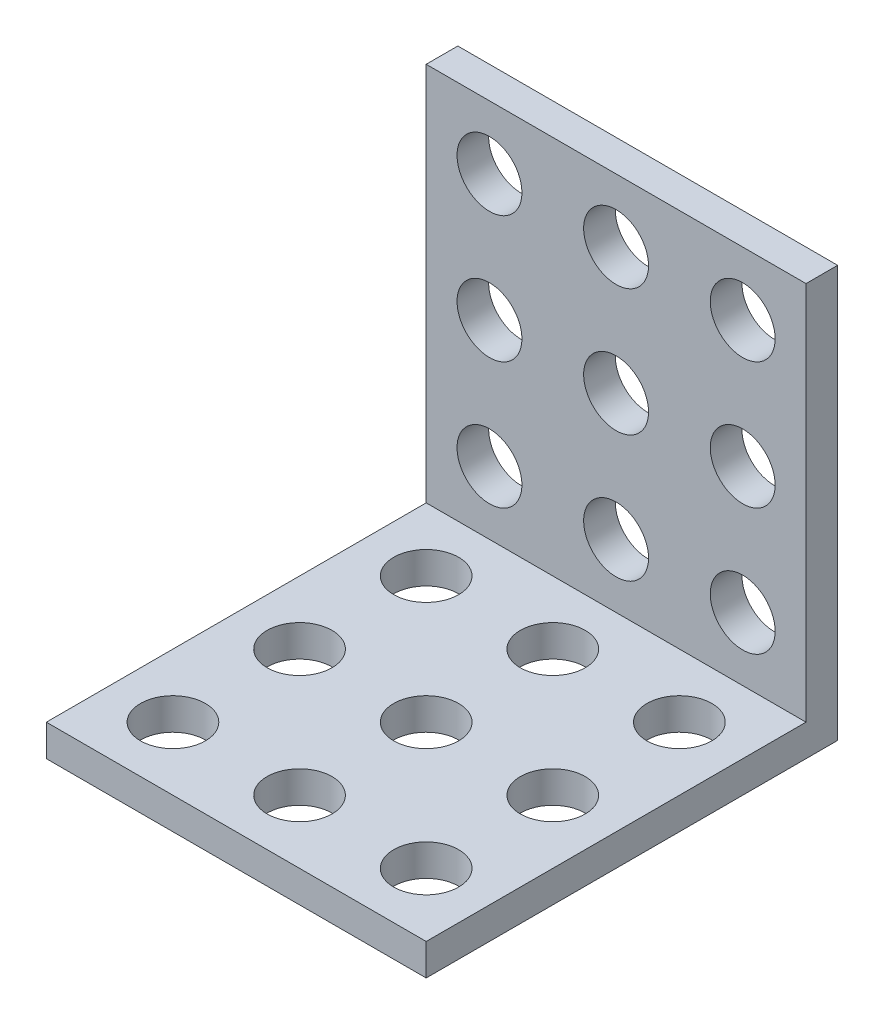
from build123d import *

# Parameters (mm, degrees)
BOSS_EXTRUDE1_DEPTH     = 12
SKETCH3_R               = 2.05
CUT_EXTRUDE1_DEPTH      = 25
CUT_EXTRUDE1_DEPTH_BACK = 3
SKETCH4_R               = 2.05
CUT_EXTRUDE2_DEPTH      = 3


with BuildPart() as part:
    # Sketch1 → Boss-Extrude1 (new body, symmetric)
    with BuildSketch(Plane(origin=(0, 0, 0), x_dir=(0, 0, -1), z_dir=(1, 0, 0))):
        Polygon((0, 0), (0, 26), (-2, 26), (-2, 2), (-26, 2), (-26, 0), align=None)
    extrude(amount=BOSS_EXTRUDE1_DEPTH, both=True)

    # Sketch3 → Cut-Extrude1 (cut, two sides)
    with BuildSketch(Plane.XY.offset(2)) as cut_extrude1_sk:
        with Locations((-8, 22)):
            Circle(SKETCH3_R)
        with Locations((0, 22)):
            Circle(SKETCH3_R)
        with Locations((8, 22)):
            Circle(SKETCH3_R)
        with Locations((0, 14)):
            Circle(SKETCH3_R)
        with Locations((8, 14)):
            Circle(SKETCH3_R)
        with Locations((0, 6)):
            Circle(SKETCH3_R)
        with Locations((8, 6)):
            Circle(SKETCH3_R)
        with Locations((-8, 14)):
            Circle(SKETCH3_R)
        with Locations((-8, 6)):
            Circle(SKETCH3_R)
    extrude(amount=CUT_EXTRUDE1_DEPTH, mode=Mode.SUBTRACT)
    extrude(cut_extrude1_sk.sketch, amount=-CUT_EXTRUDE1_DEPTH_BACK, mode=Mode.SUBTRACT)

    # Sketch4 → Cut-Extrude2 (cut, through all)
    with BuildSketch(Plane(origin=(0, 2, 0), x_dir=(1, 0, 0), z_dir=(0, 1, 0))):
        with Locations((-8, -22)):
            Circle(SKETCH4_R)
        with Locations((0, -22)):
            Circle(SKETCH4_R)
        with Locations((8, -22)):
            Circle(SKETCH4_R)
        with Locations((0, -14)):
            Circle(SKETCH4_R)
        with Locations((8, -14)):
            Circle(SKETCH4_R)
        with Locations((0, -6)):
            Circle(SKETCH4_R)
        with Locations((8, -6)):
            Circle(SKETCH4_R)
        with Locations((-8, -14)):
            Circle(SKETCH4_R)
        with Locations((-8, -6)):
            Circle(SKETCH4_R)
    extrude(amount=-CUT_EXTRUDE2_DEPTH, mode=Mode.SUBTRACT)


solid = part.part
